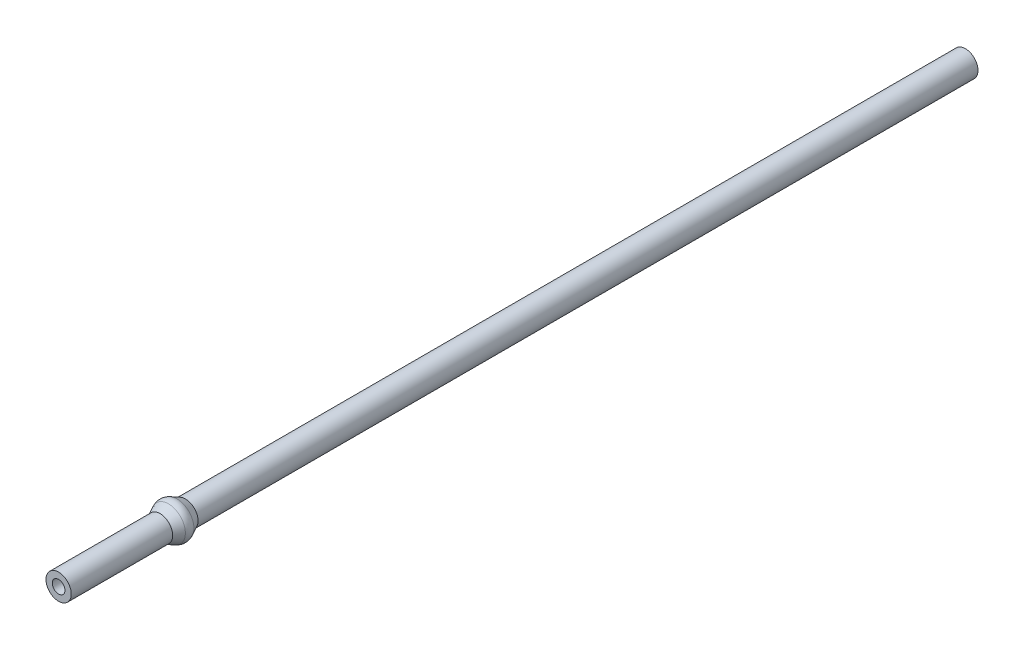
from build123d import *

# Parameters (mm, degrees)
SKETCH1_R           = 1.58242
BOSS_EXTRUDE1_DEPTH = 113.50625
SKETCH2_R           = 0.79375
CUT_EXTRUDE1_DEPTH  = 3.175
SKETCH3_R           = 0.396875
CUT_EXTRUDE2_DEPTH  = 14.2875
CUT_EXTRUDE4_START  = -14.2875
SKETCH4_R           = 0.79375
CUT_EXTRUDE4_DEPTH  = 100.21875


with BuildPart() as part:
    # Sketch1 → Boss-Extrude1 (new body)
    with BuildSketch(Plane.XY):
        Circle(SKETCH1_R)
    extrude(amount=-BOSS_EXTRUDE1_DEPTH)

    # Sketch2 → Cut-Extrude1 (cut)
    with BuildSketch(Plane.XY):
        Circle(SKETCH2_R)
    extrude(amount=-CUT_EXTRUDE1_DEPTH, mode=Mode.SUBTRACT)

    # Sketch3 → Cut-Extrude2 (cut)
    with BuildSketch(Plane.XY):
        Circle(SKETCH3_R)
    extrude(amount=-CUT_EXTRUDE2_DEPTH, mode=Mode.SUBTRACT)

    # Sketch4 → Cut-Extrude4 (cut, through all)
    with BuildSketch(Plane.XY.offset(CUT_EXTRUDE4_START)):
        Circle(SKETCH4_R)
    extrude(amount=-CUT_EXTRUDE4_DEPTH, mode=Mode.SUBTRACT)

    # Sketch5 → Revolve1 (revolve)
    with BuildSketch(Plane(origin=(0, 0, 0), x_dir=(0, 0, -1), z_dir=(1, 0, 0))):
        with BuildLine():
            Line((12.7, 1.58242), (13.752029901, 2.111801446))
            ThreePointArc((13.752029901, 2.111801446), (14.2875, 2.238931679), (14.822970099, 2.111801446))
            Line((14.822970099, 2.111801446), (15.875, 1.58242))
            Line((15.875, 1.58242), (12.7, 1.58242))
        make_face()
    revolve(axis=Axis((0, 0, 0), (0, 0, -1)))


solid = part.part
